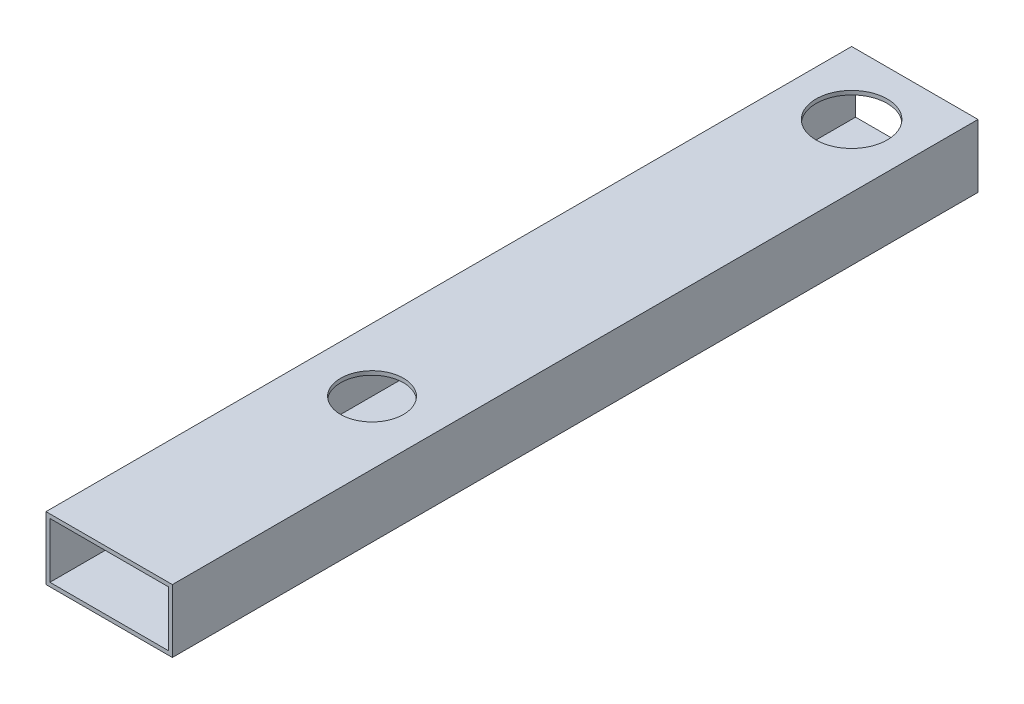
from build123d import *

# Parameters (mm, degrees)
SKETCH1_W           = 50.8
SKETCH1_H           = 25.4
SKETCH1_W_2         = 47.625
SKETCH1_H_2         = 22.225
BOSS_EXTRUDE1_DEPTH = 323.85
SKETCH2_R           = 14.305600685
CUT_EXTRUDE1_DEPTH  = 26.4
SKETCH4_R           = 12.637898421
CUT_EXTRUDE3_DEPTH  = 26.4


with BuildPart() as part:
    # Sketch1 → Boss-Extrude1 (new body)
    with BuildSketch(Plane.XY):
        with Locations((18.190104167, -7.24296875)):
            Rectangle(SKETCH1_W, SKETCH1_H)
        with Locations((18.190104167, -7.24296875)):
            Rectangle(SKETCH1_W_2, SKETCH1_H_2, mode=Mode.SUBTRACT)
    extrude(amount=BOSS_EXTRUDE1_DEPTH)

    # Sketch2 → Cut-Extrude1 (cut, through all)
    with BuildSketch(Plane(origin=(0, 5.45703125, 0), x_dir=(1, 0, 0), z_dir=(0, 1, 0))):
        with Locations((18.190104167, -25.4)):
            Circle(SKETCH2_R)
    extrude(amount=-CUT_EXTRUDE1_DEPTH, mode=Mode.SUBTRACT)

    # Sketch4 → Cut-Extrude3 (cut, through all)
    with BuildSketch(Plane(origin=(0, 5.45703125, 0), x_dir=(1, 0, 0), z_dir=(0, 1, 0))):
        with Locations((18.190104167, -218.186)):
            Circle(SKETCH4_R)
    extrude(amount=-CUT_EXTRUDE3_DEPTH, mode=Mode.SUBTRACT)


solid = part.part
